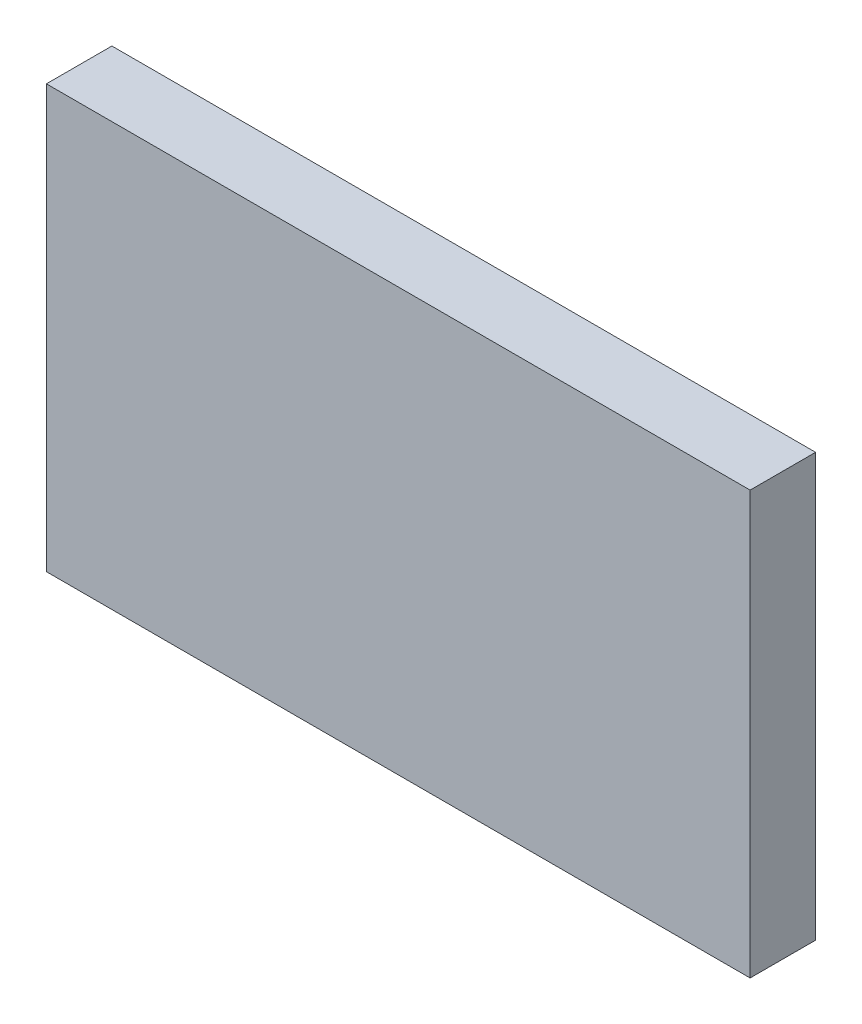
from build123d import *

# Parameters (mm, degrees)
ESQUISSE1_W        = 107.46483146
ESQUISSE1_H        = 64.52741573
BOSS_EXTRU_1_DEPTH = 10


with BuildPart() as part:
    # Esquisse1 → Boss.-Extru.1 (new body)
    with BuildSketch(Plane.XY):
        with Locations((-5.554008128, -1.940674157)):
            Rectangle(ESQUISSE1_W, ESQUISSE1_H)
    extrude(amount=BOSS_EXTRU_1_DEPTH)


solid = part.part
